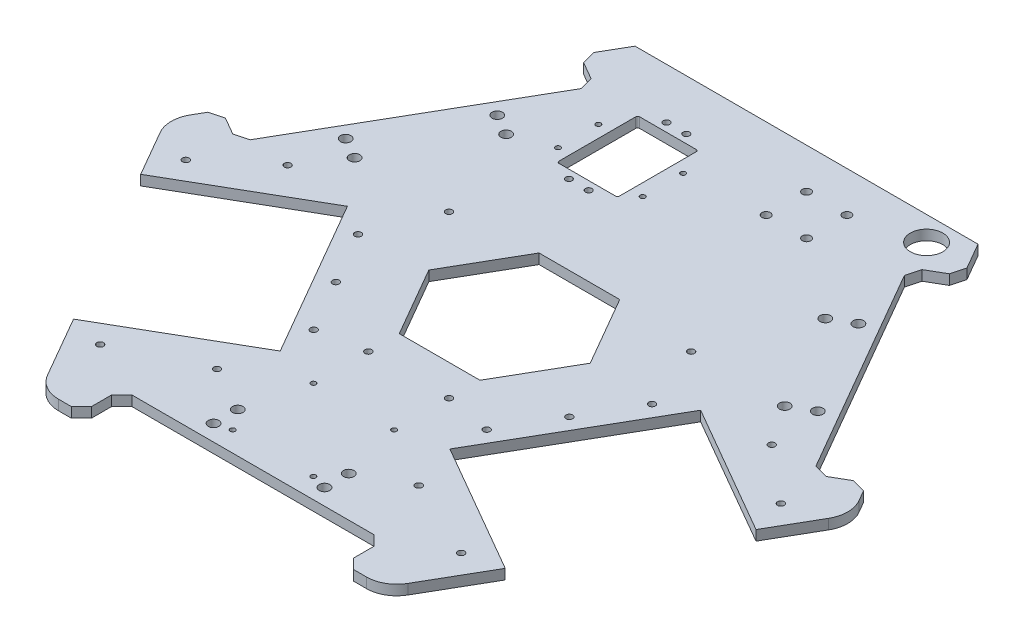
from build123d import *

# Parameters (mm, degrees)
EXTRUDE_1_DEPTH             = 5
CUT_EXTRUDE_31_REACH        = 226.944
SKETCH_46_W                 = 130
SKETCH_46_H                 = 20
SKETCH_8_R                  = 2.6
CUT_EXTRUDE_6_DEPTH         = 225.944437584
PATTERN_CIRCULAR_1_COUNT    = 3
CHAMFER_1_SIZE              = 5
CUT_EXTRUDE_4_DEPTH         = 225.944437584
SKETCH_9_R                  = 1.65
CUT_EXTRUDE_7_DEPTH         = 225.944437584
FILLET_1_R                  = 15
M4X0_7_4_D                  = 3.3
CUT_EXTRUDE_35_REACH        = 225.196
CUT_EXTRUDE_37_REACH        = 225.196
SKETCH_53_R                 = 2.1
PATTERN_LINEAR_1_COUNT      = 2
PATTERN_LINEAR_1_PITCH      = 20
PATTERN_LINEAR_1_COUNT_DIR2 = 2
PATTERN_LINEAR_1_PITCH_DIR2 = 20
CUT_EXTRUDE_38_REACH        = 225.196
SKETCH_54_R                 = 8.05
SKETCH_56_R                 = 1.6
CUT_EXTRUDE_40_DEPTH        = 10
SKETCH_55_W                 = 30
SKETCH_55_H                 = 40
CUT_EXTRUDE_39_DEPTH        = 10
FILLET_2_R                  = 1
M3X0_5_1_D                  = 2.5
M3X0_5_1_DEPTH              = 8.5
M3X0_5_1_TIP                = 0.751075774
M4X0_7_5_AT_2_COUNT         = 2
M4X0_7_5_AT_2_PITCH         = 126.194294641
M4X0_7_5_AT_3_COUNT         = 2
M4X0_7_5_AT_3_PITCH         = 125.39936204
M4X0_7_5_AT_4_COUNT         = 2
M4X0_7_5_AT_4_PITCH         = 54.083269132
M3X0_5_2_D                  = 2.5
M3X0_5_2_DEPTH              = 8.5
M3X0_5_2_TIP                = 0.751075774


with BuildPart() as part:
    # 草圖1 → 填料-伸長1 (new body)
    with BuildSketch(Plane(origin=(0, 0, 0), x_dir=(1, 0, 0), z_dir=(0, 1, 0))):
        Polygon((85, 147.224318643), (-85, 147.224318643), (-170, 0), (-85, -147.224318643), (85, -147.224318643), (170, 0), align=None)
    extrude(amount=EXTRUDE_1_DEPTH)

    # 草圖46 → 除料-伸長31 (cut, up to next)
    with BuildSketch(Plane(origin=(0, 5, 0), x_dir=(1, 0, 0), z_dir=(0, 1, 0)), mode=Mode.PRIVATE) as cut_extrude_31_sk1:
        with Locations((0, -137.224318643)):
            Rectangle(SKETCH_46_W, SKETCH_46_H)
    cut_extrude_31_tool1 = extrude(cut_extrude_31_sk1.sketch, amount=-CUT_EXTRUDE_31_REACH, mode=Mode.PRIVATE) & part.part
    cut_extrude_31 = cut_extrude_31_tool1.solids().sort_by_distance((0, 5, 137.224319))[0]
    add(cut_extrude_31, mode=Mode.SUBTRACT)

    # 草圖8 → 除料-伸長6 (cut, through all)
    with BuildSketch(Plane(origin=(0, 5, 0), x_dir=(1, 0, 0), z_dir=(0, 1, 0))):
        with Locations((-27.5, -119.224318643)):
            Circle(SKETCH_8_R)
        with Locations((27.5, -119.224318643)):
            Circle(SKETCH_8_R)
        with Locations((-27.5, -107.224318643)):
            Circle(SKETCH_8_R)
        with Locations((27.5, -107.224318643)):
            Circle(SKETCH_8_R)
    cut_extrude_6 = extrude(amount=-CUT_EXTRUDE_6_DEPTH, mode=Mode.SUBTRACT)

    # 環狀複製排列1: 除料-伸長31, 除料-伸長6 ×3 about axis
    pattern_circular_1_axis = Axis((0, -0.25, 0), (0, 1, 0))
    add([cut_extrude_31.rotate(pattern_circular_1_axis, i * 360 / PATTERN_CIRCULAR_1_COUNT) for i in range(1, PATTERN_CIRCULAR_1_COUNT)], mode=Mode.SUBTRACT)
    add([cut_extrude_6.rotate(pattern_circular_1_axis, i * 360 / PATTERN_CIRCULAR_1_COUNT) for i in range(1, PATTERN_CIRCULAR_1_COUNT)], mode=Mode.SUBTRACT)

    # 導角1
    chamfer_1_edges = [part.edges().sort_by_distance(p)[0] for p in [
        (65, 2.5, 127.224318643),
        (65, 2.5, 147.224318643),
        (-65, 2.5, 147.224318643),
        (-65, 2.5, 127.224318643),
        (77.679491924, 2.5, -119.903810568),
        (95, 2.5, -129.903810568),
        (160, 2.5, -17.320508076),
        (142.679491924, 2.5, -7.320508076),
        (-160, 2.5, -17.320508076),
        (-142.679491924, 2.5, -7.320508076),
        (-77.679491924, 2.5, -119.903810568),
        (-95, 2.5, -129.903810568),
    ]]
    chamfer(chamfer_1_edges, length=CHAMFER_1_SIZE)

    # 草圖5 → 除料-伸長4 (cut, through all)
    with BuildSketch(Plane(origin=(0, 5, 0), x_dir=(1, 0, 0), z_dir=(0, 1, 0))):
        Polygon((-152.5, -30.310889132), (-107, -109.119200877), (-42.048094716, -71.619200877), (-87.548094716, 7.189110868), align=None)
    cut_extrude_4 = extrude(amount=-CUT_EXTRUDE_4_DEPTH, mode=Mode.SUBTRACT)

    # 草圖9 → 除料-伸長7 (cut, through all)
    with BuildSketch(Plane(origin=(0, 5, 0), x_dir=(1, 0, 0), z_dir=(0, 1, 0))):
        with Locations((-89.491669751, -113.444518424)):
            Circle(SKETCH_9_R)
        with Locations((-147.491669751, -12.985571585)):
            Circle(SKETCH_9_R)
    cut_extrude_7 = extrude(amount=-CUT_EXTRUDE_7_DEPTH, mode=Mode.SUBTRACT)

    # 鏡射1: 除料-伸長4, 除料-伸長7 across plane
    add(cut_extrude_4.mirror(Plane(origin=(0, 0, 0), x_dir=(0, 0, 1), z_dir=(1, 0, 0))), mode=Mode.SUBTRACT)
    add(cut_extrude_7.mirror(Plane(origin=(0, 0, 0), x_dir=(0, 0, 1), z_dir=(1, 0, 0))), mode=Mode.SUBTRACT)

    # 圓角1
    fillet_1_edges = [part.edges().sort_by_distance(p)[0] for p in [
        (170, 2.5, 0),
        (85, 2.5, 147.224318643),
        (-170, 2.5, 0),
        (-85, 2.5, 147.224318643),
    ]]
    fillet(fillet_1_edges, radius=FILLET_1_R)

    # M4x0.7 螺紋孔4 (through all)
    with Locations(Plane(origin=(0, 5, 0), x_dir=(1, 0, 0), z_dir=(0, 1, 0))):
        with Locations((-72.869891486, -2.234282891), (-57.869891486, -28.215045005), (-42.869891486, -54.195807118)):
            m4x0_7_4 = Hole(M4X0_7_4_D / 2)

    # 鏡射2: M4x0.7 螺紋孔4 across plane
    add(m4x0_7_4.mirror(Plane(origin=(0, 0, 0), x_dir=(0, 0, 1), z_dir=(1, 0, 0))), mode=Mode.SUBTRACT)

    # 草圖51 → 除料-伸長35 (cut, up to next)
    with BuildSketch(Plane(origin=(0, 5, 0), x_dir=(1, 0, 0), z_dir=(0, 1, 0)), mode=Mode.PRIVATE) as cut_extrude_35_sk1:
        Polygon((20, 34.641016151), (-20, 34.641016151), (-40, 0), (-20, -34.641016151), (20, -34.641016151), (40, 0), align=None)
    cut_extrude_35_tool1 = extrude(cut_extrude_35_sk1.sketch, amount=-CUT_EXTRUDE_35_REACH, mode=Mode.PRIVATE) & part.part
    add(cut_extrude_35_tool1.solids().sort_by_distance((0, 5, 0))[0], mode=Mode.SUBTRACT)

    # 草圖53 → 除料-伸長37 (cut, up to next)
    with BuildSketch(Plane(origin=(0, 5, 0), x_dir=(1, 0, 0), z_dir=(0, 1, 0)), mode=Mode.PRIVATE) as cut_extrude_37_sk1:
        with Locations((20, 127.224318643)):
            Circle(SKETCH_53_R)
    cut_extrude_37_tool1 = extrude(cut_extrude_37_sk1.sketch, amount=-CUT_EXTRUDE_37_REACH, mode=Mode.PRIVATE) & part.part
    cut_extrude_37 = cut_extrude_37_tool1.solids().sort_by_distance((20, 5, -127.224319))[0]
    add(cut_extrude_37, mode=Mode.SUBTRACT)

    # 直線複製排列1: Cut-Extrude 37 2 × 2
    with Locations(*[(i * PATTERN_LINEAR_1_PITCH, 0, j * PATTERN_LINEAR_1_PITCH_DIR2) for i in range(PATTERN_LINEAR_1_COUNT) for j in range(PATTERN_LINEAR_1_COUNT_DIR2) if (i, j) != (0, 0)]):
        add(cut_extrude_37, mode=Mode.SUBTRACT)

    # 草圖54 → 除料-伸長38 (cut, up to next)
    with BuildSketch(Plane(origin=(0, 5, 0), x_dir=(1, 0, 0), z_dir=(0, 1, 0)), mode=Mode.PRIVATE) as cut_extrude_38_sk1:
        with Locations((71.5, 135.224318643)):
            Circle(SKETCH_54_R)
    cut_extrude_38_tool1 = extrude(cut_extrude_38_sk1.sketch, amount=-CUT_EXTRUDE_38_REACH, mode=Mode.PRIVATE) & part.part
    add(cut_extrude_38_tool1.solids().sort_by_distance((71.5, 5, -135.224319))[0], mode=Mode.SUBTRACT)

    # 草圖56 → 除料-伸長40 (cut)
    with BuildSketch(Plane(origin=(0, 0, 0), x_dir=(-1, 0, 0), z_dir=(0, -1, 0))):
        with Locations((34.6, 122.224318643)):
            Circle(SKETCH_56_R)
        with Locations((44.4, 122.224318643)):
            Circle(SKETCH_56_R)
        with Locations((44.4, 73.824318643)):
            Circle(SKETCH_56_R)
        with Locations((34.6, 73.824318643)):
            Circle(SKETCH_56_R)
    extrude(amount=-CUT_EXTRUDE_40_DEPTH, mode=Mode.SUBTRACT)

    # 草圖55 → 除料-伸長39 (cut)
    with BuildSketch(Plane(origin=(0, 5, 0), x_dir=(1, 0, 0), z_dir=(0, 1, 0))):
        with Locations((-39.5, 98.024318643)):
            Rectangle(SKETCH_55_W, SKETCH_55_H)
    extrude(amount=-CUT_EXTRUDE_39_DEPTH, mode=Mode.SUBTRACT)

    # 圓角2
    fillet_2_edges = [part.edges().sort_by_distance(p)[0] for p in [
        (-54.5, 2.5, -78.024318643),
        (-24.5, 2.5, -78.024318643),
        (-24.5, 2.5, -118.024318643),
        (-54.5, 2.5, -118.024318643),
    ]]
    fillet(fillet_2_edges, radius=FILLET_2_R)

    # M3x0.5 螺紋孔1
    with Locations(Plane(origin=(0, 5, 0), x_dir=(1, 0, 0), z_dir=(0, 1, 0))):
        with Locations((-60.5, 104.524318643), (-60.5, 84.524318643), (-18.5, 84.524318643), (-18.5, 104.524318643)):
            Hole(M3X0_5_1_D / 2, depth=M3X0_5_1_DEPTH)
            with Locations((0, 0, -(M3X0_5_1_DEPTH + M3X0_5_1_TIP / 2))):  # 118° drill point
                Cone(0, M3X0_5_1_D / 2, M3X0_5_1_TIP, mode=Mode.SUBTRACT)

    # 草圖61 → M4x0.7 螺紋孔5 (revolve, cut)
    with BuildSketch(Plane(origin=(-50, 5, 95), x_dir=(0, 0, 1), z_dir=(1, 0, 0))):
        Polygon((0, 0), (0, 12.491420021), (1.65, 11.5), (1.65, 0), align=None)
    m4x0_7_5 = revolve(axis=Axis((-50, 11.35, 95), (0, -1, 0)), mode=Mode.SUBTRACT)

    # M4x0.7 螺紋孔5 at 2: M4x0.7 螺紋孔5 ×2
    with Locations(*[Vector(-0.5547001962252291, 0, -0.8320502943378437) * (i * M4X0_7_5_AT_2_PITCH) for i in range(1, M4X0_7_5_AT_2_COUNT)]):
        add(m4x0_7_5, mode=Mode.SUBTRACT)

    # M4x0.7 螺紋孔5 at 3: M4x0.7 螺紋孔5 ×2
    with Locations(*[Vector(-0.07974522228289006, 0, -0.9968152785361251) * (i * M4X0_7_5_AT_3_PITCH) for i in range(1, M4X0_7_5_AT_3_COUNT)]):
        add(m4x0_7_5, mode=Mode.SUBTRACT)

    # M4x0.7 螺紋孔5 at 4: M4x0.7 螺紋孔5 ×2
    with Locations(*[Vector(0.5547001962252291, 0, -0.8320502943378437) * (i * M4X0_7_5_AT_4_PITCH) for i in range(1, M4X0_7_5_AT_4_COUNT)]):
        add(m4x0_7_5, mode=Mode.SUBTRACT)

    # 鏡射3: M4x0.7 螺紋孔5 across plane
    add(m4x0_7_5.mirror(Plane(origin=(0, 0, 0), x_dir=(0, 0, 1), z_dir=(1, 0, 0))), mode=Mode.SUBTRACT)

    # 鏡射3 copy 1 sketch → 鏡射3 copy 1 (revolve, cut)
    with BuildSketch(Plane(origin=(120, 5, -10), x_dir=(0, 0, 1), z_dir=(-1, 0, 0))):
        Polygon((0, 0), (0, -12.491420021), (1.65, -11.5), (1.65, 0), align=None)
    revolve(axis=Axis((120, 11.35, -10), (0, 1, 0)), mode=Mode.SUBTRACT)

    # 鏡射3 copy 2 sketch → 鏡射3 copy 2 (revolve, cut)
    with BuildSketch(Plane(origin=(60, 5, -30), x_dir=(0, 0, 1), z_dir=(-1, 0, 0))):
        Polygon((0, 0), (0, -12.491420021), (1.65, -11.5), (1.65, 0), align=None)
    revolve(axis=Axis((60, 11.35, -30), (0, 1, 0)), mode=Mode.SUBTRACT)

    # 鏡射3 copy 3 sketch → 鏡射3 copy 3 (revolve, cut)
    with BuildSketch(Plane(origin=(20, 5, 50), x_dir=(0, 0, 1), z_dir=(-1, 0, 0))):
        Polygon((0, 0), (0, -12.491420021), (1.65, -11.5), (1.65, 0), align=None)
    revolve(axis=Axis((20, 11.35, 50), (0, 1, 0)), mode=Mode.SUBTRACT)

    # M3x0.5 螺紋孔2
    with Locations(Plane(origin=(0, 5, 0), x_dir=(1, 0, 0), z_dir=(0, 1, 0))):
        with Locations((-20, -77.224318643), (-20, -117.224318643), (20, -117.224318643), (20, -77.224318643)):
            Hole(M3X0_5_2_D / 2, depth=M3X0_5_2_DEPTH)
            with Locations((0, 0, -(M3X0_5_2_DEPTH + M3X0_5_2_TIP / 2))):  # 118° drill point
                Cone(0, M3X0_5_2_D / 2, M3X0_5_2_TIP, mode=Mode.SUBTRACT)


solid = part.part
